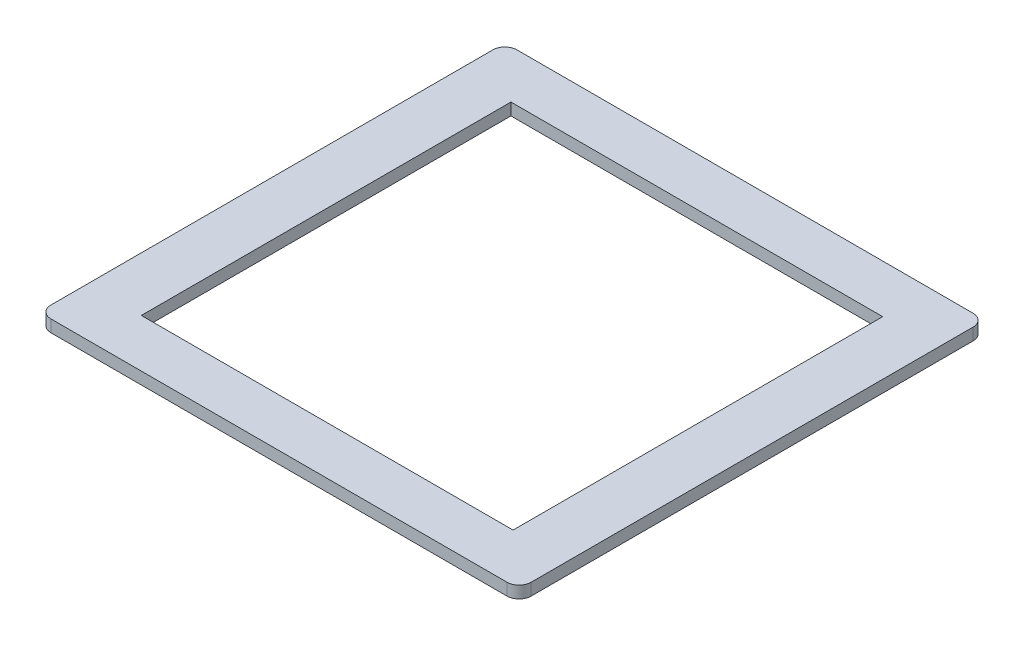
from build123d import *

# Parameters (mm, degrees)
SKETCH_3_W      = 61.702142611
SKETCH_3_H      = 61.347239899
EXTRUDE_1_DEPTH = 2


with BuildPart() as part:
    # 草图3 → 凸台-拉伸1 (new body)
    with BuildSketch(Plane(origin=(161.680584905, -5752.54008863, -301.131668073), x_dir=(1, 0, 0), z_dir=(0, 1, 0))):
        with BuildLine():
            Line((-118.231072015, -152.924864972), (-42.528929404, -152.924864972))
            ThreePointArc((-42.528929404, -152.924864972), (-41.114715842, -153.510651409), (-40.528929404, -154.924864972))
            Line((-40.528929404, -154.924864972), (-40.528929404, -228.272104871))
            ThreePointArc((-40.528929404, -228.272104871), (-41.114715842, -229.686318433), (-42.528929404, -230.272104871))
            Line((-42.528929404, -230.272104871), (-118.231072015, -230.272104871))
            ThreePointArc((-118.231072015, -230.272104871), (-119.645285578, -229.686318433), (-120.231072015, -228.272104871))
            Line((-120.231072015, -228.272104871), (-120.231072015, -154.924864972))
            ThreePointArc((-120.231072015, -154.924864972), (-119.645285578, -153.510651409), (-118.231072015, -152.924864972))
        make_face()
        with Locations((-80.38000071, -191.598484922)):
            Rectangle(SKETCH_3_W, SKETCH_3_H, mode=Mode.SUBTRACT)
    extrude(amount=EXTRUDE_1_DEPTH)


solid = part.part
